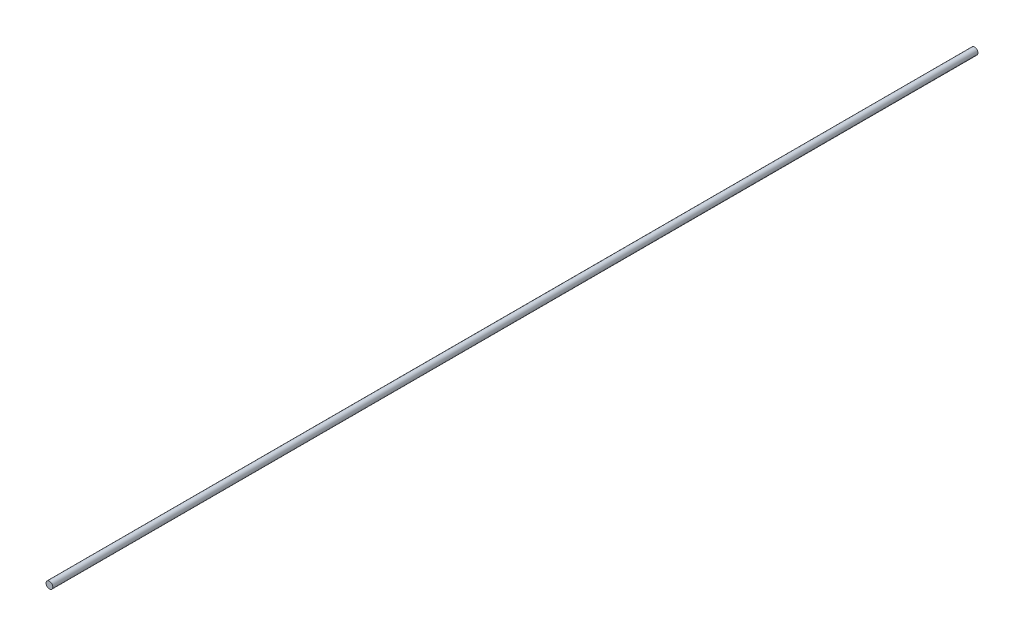
from build123d import *

# Parameters (mm, degrees)
SKETCH1_R           = 6.35
BOSS_EXTRUDE1_DEPTH = 863.6


with BuildPart() as part:
    # Sketch1 → Boss-Extrude1 (new body, symmetric)
    with BuildSketch(Plane.XY):
        Circle(SKETCH1_R)
    extrude(amount=BOSS_EXTRUDE1_DEPTH, both=True)


solid = part.part
